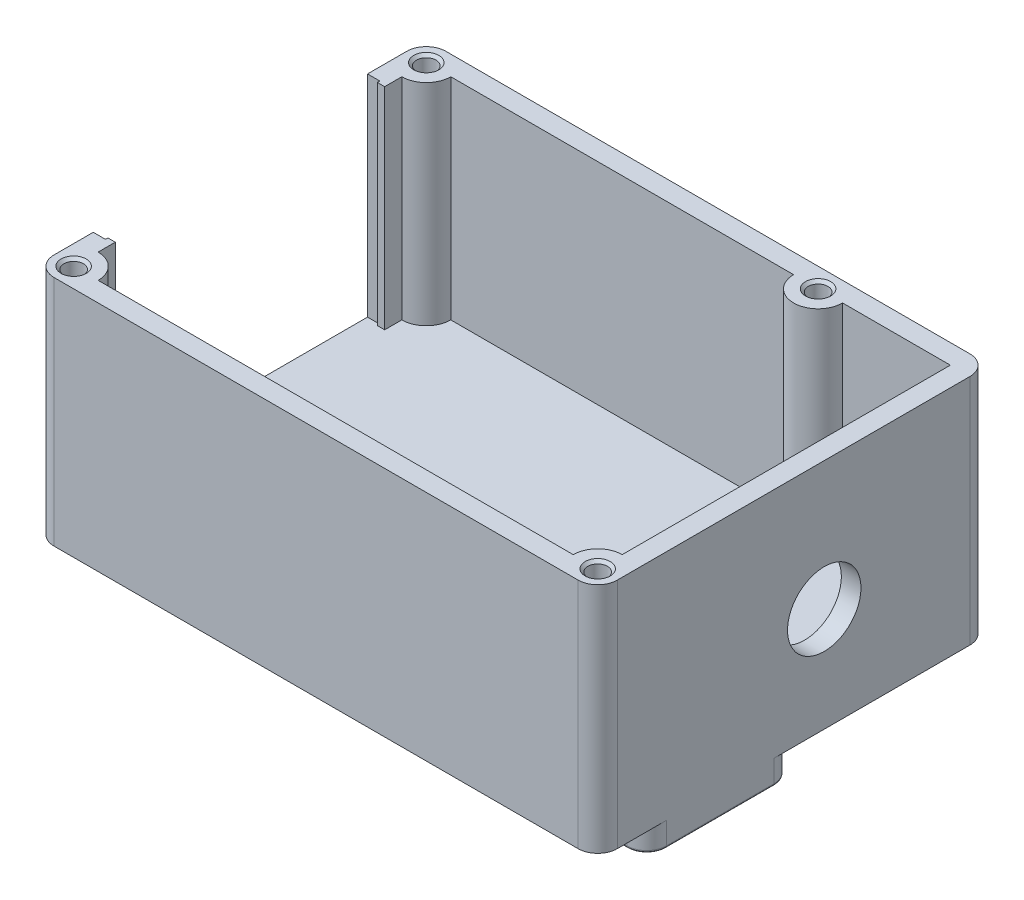
from build123d import *

# Parameters (mm, degrees)
SKETCH1_W                       = 46
SKETCH1_H                       = 32
BOSS_EXTRUDE1_DEPTH             = 19
M2X0_4_TAPPED_HOLE1_D           = 1.6
M2X0_4_TAPPED_HOLE1_DEPTH       = 6
M2X0_4_TAPPED_HOLE1_CSINK_D     = 2.05
M2X0_4_TAPPED_HOLE1_CSINK_ANGLE = 90
M2X0_4_TAPPED_HOLE1_TIP         = 0.480688495
SKETCH4_R                       = 4
SKETCH4_R_2                     = 3.5
BOSS_EXTRUDE2_DEPTH             = 2
SKETCH5_W                       = 13
SKETCH5_H                       = 12
BOSS_EXTRUDE4_DEPTH             = 2
FILLET1_R                       = 1.6
FILLET2_R                       = 1.6
FILLET3_R                       = 0.2
CUT_EXTRUDE3_DEPTH              = 17.2
SKETCH6_W                       = 2
SKETCH6_H                       = 22
CUT_EXTRUDE1_DEPTH              = 17.2
SKETCH7_W                       = 1
SKETCH7_H                       = 22.4
CUT_EXTRUDE2_DEPTH              = 17.2
SKETCH9_R                       = 3
CUT_EXTRUDE4_DEPTH              = 47


with BuildPart() as part:
    # Sketch1 → Boss-Extrude1 (new body)
    with BuildSketch(Plane(origin=(0, 0, 0), x_dir=(1, 0, 0), z_dir=(0, 1, 0))):
        with Locations((9, 0)):
            Rectangle(SKETCH1_W, SKETCH1_H)
    extrude(amount=-BOSS_EXTRUDE1_DEPTH)

    # M2x0.4 Tapped Hole1
    with Locations(Plane(origin=(0, 0, 0), x_dir=(1, 0, 0), z_dir=(0, 1, 0))):
        with Locations((-12.4, 14.4), (19.6, 14.4), (30.4, -14.4), (-12.4, -14.4)):
            CounterSinkHole(M2X0_4_TAPPED_HOLE1_D / 2, M2X0_4_TAPPED_HOLE1_CSINK_D / 2, depth=M2X0_4_TAPPED_HOLE1_DEPTH, counter_sink_angle=M2X0_4_TAPPED_HOLE1_CSINK_ANGLE)
            with Locations((0, 0, -(M2X0_4_TAPPED_HOLE1_DEPTH + M2X0_4_TAPPED_HOLE1_TIP / 2))):  # 118° drill point
                Cone(0, M2X0_4_TAPPED_HOLE1_D / 2, M2X0_4_TAPPED_HOLE1_TIP, mode=Mode.SUBTRACT)

    # Sketch4 → Boss-Extrude2 (add)
    with BuildSketch(Plane(origin=(0, -19, 0), x_dir=(-1, 0, 0), z_dir=(0, -1, 0))):
        Circle(SKETCH4_R)
        with Locations((-12, -5.5)):
            Circle(SKETCH4_R_2)
        with Locations((-12, 5.5)):
            Circle(SKETCH4_R_2)
    extrude(amount=BOSS_EXTRUDE2_DEPTH)

    # Sketch5 → Boss-Extrude4 (add)
    with BuildSketch(Plane(origin=(0, -19, 0), x_dir=(1, 0, 0), z_dir=(0, 1, 0))):
        with Locations((25.5, -6)):
            Rectangle(SKETCH5_W, SKETCH5_H)
    extrude(amount=-BOSS_EXTRUDE4_DEPTH)

    # Fillet1
    fillet1_edges = [part.edges().sort_by_distance(p)[0] for p in [
        (-14, -9.5, -16),
        (32, -9.5, -16),
        (32, -9.5, 16),
        (-14, -9.5, 16),
    ]]
    fillet(fillet1_edges, radius=FILLET1_R)

    # Fillet2
    fillet2_edges = [part.edges().sort_by_distance(p)[0] for p in [
        (19, -20, 12),
        (19, -20, 0),
        (32, -20, 0),
        (32, -20, 12),
    ]]
    fillet(fillet2_edges, radius=FILLET2_R)

    # Fillet3
    fillet3_edges = [part.edges().sort_by_distance(p)[0] for p in [
        (4, -21, 0),
        (15.5, -21, 5.5),
        (15.5, -21, -5.5),
        (25.5, -21, 12),
        (32, -21, 6),
        (19, -21, 6),
        (25.5, -21, 0),
        (31.53137085, -21, 0.46862915),
        (19.46862915, -21, 0.46862915),
        (19.46862915, -21, 11.53137085),
        (31.53137085, -21, 11.53137085),
    ]]
    fillet(fillet3_edges, radius=FILLET3_R)

    # Sketch8 → Cut-Extrude3 (cut)
    with BuildSketch(Plane(origin=(0, 0, 0), x_dir=(1, 0, 0), z_dir=(0, 1, 0))):
        with BuildLine():
            Line((-10.4, 14.4), (17.6, 14.4))
            ThreePointArc((17.6, 14.4), (19.6, 12.4), (21.6, 14.4))
            Line((21.6, 14.4), (30.4, 14.4))
            Line((30.4, 14.4), (30.4, -12.4))
            ThreePointArc((30.4, -12.4), (28.985786438, -12.985786438), (28.4, -14.4))
            Line((28.4, -14.4), (-10.4, -14.4))
            ThreePointArc((-10.4, -14.4), (-10.985786438, -12.985786438), (-12.4, -12.4))
            Line((-12.4, -12.4), (-12.4, 12.4))
            ThreePointArc((-12.4, 12.4), (-10.985786438, 12.985786438), (-10.4, 14.4))
        make_face()
    extrude(amount=-CUT_EXTRUDE3_DEPTH, mode=Mode.SUBTRACT)

    # Sketch6 → Cut-Extrude1 (cut)
    with BuildSketch(Plane(origin=(0, 0, 0), x_dir=(1, 0, 0), z_dir=(0, 1, 0))):
        with Locations((-13, 0)):
            Rectangle(SKETCH6_W, SKETCH6_H)
    extrude(amount=-CUT_EXTRUDE1_DEPTH, mode=Mode.SUBTRACT)

    # Sketch7 → Cut-Extrude2 (cut)
    with BuildSketch(Plane(origin=(0, 0, 0), x_dir=(1, 0, 0), z_dir=(0, 1, 0))):
        with Locations((-13.5, 0)):
            Rectangle(SKETCH7_W, SKETCH7_H)
    extrude(amount=-CUT_EXTRUDE2_DEPTH, mode=Mode.SUBTRACT)

    # Sketch9 → Cut-Extrude4 (cut, through all)
    with BuildSketch(Plane(origin=(32, 0, 0), x_dir=(0, 0, -1), z_dir=(1, 0, 0))):
        with Locations((2.5, -10.5)):
            Circle(SKETCH9_R)
    extrude(amount=-CUT_EXTRUDE4_DEPTH, mode=Mode.SUBTRACT)


solid = part.part
